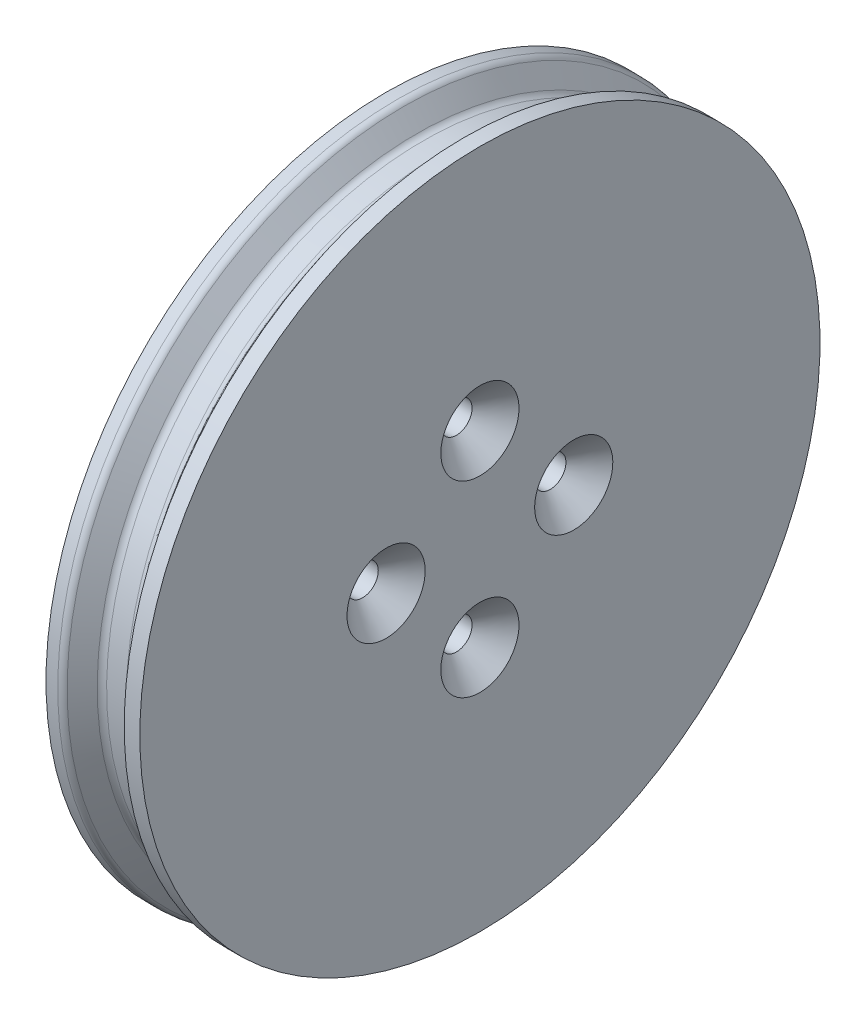
from build123d import *

# Parameters (mm, degrees)
SCHIZZO2_R               = 1
TAGLIO_ESTRUSIONE1_DEPTH = 10
SMUSSO1_SIZE             = 1.5
RACCORDO1_R              = 0.5


with BuildPart() as part:
    # Schizzo1 → Rivoluzione1 (revolve)
    with BuildSketch(Plane.XY):
        Polygon((0, 0), (0, 17.3), (-3, 17.3), (-3, 21.75), (-2, 21.75), (-0.875, 20.25), (0.875, 20.25), (2, 21.75), (3, 21.75), (3, 0), align=None)
    revolve(axis=Axis((0, 0, 0), (1, 0, 0)))

    # Schizzo2 → Taglio-Estrusione1 (cut)
    with BuildSketch(Plane(origin=(3, 0, 0), x_dir=(0, 0, -1), z_dir=(1, 0, 0))):
        with Locations((0, 6)):
            Circle(SCHIZZO2_R)
        with Locations((6, 0)):
            Circle(SCHIZZO2_R)
        with Locations((0, -6)):
            Circle(SCHIZZO2_R)
        with Locations((-6, 0)):
            Circle(SCHIZZO2_R)
    extrude(amount=-TAGLIO_ESTRUSIONE1_DEPTH, mode=Mode.SUBTRACT)

    # Smusso1
    smusso1_edges = [part.edges().sort_by_distance(p)[0] for p in [
        (3, 6, 1),
        (3, 0, -5),
        (3, -6, 1),
        (3, 0, 7),
    ]]
    chamfer(smusso1_edges, length=SMUSSO1_SIZE)

    # Raccordo1
    raccordo1_edges = [part.edges().sort_by_distance(p)[0] for p in [
        (-2, -21.75, 0),
        (0.875, -20.25, 0),
        (-0.875, -20.25, 0),
    ]]
    fillet(raccordo1_edges, radius=RACCORDO1_R)


solid = part.part
